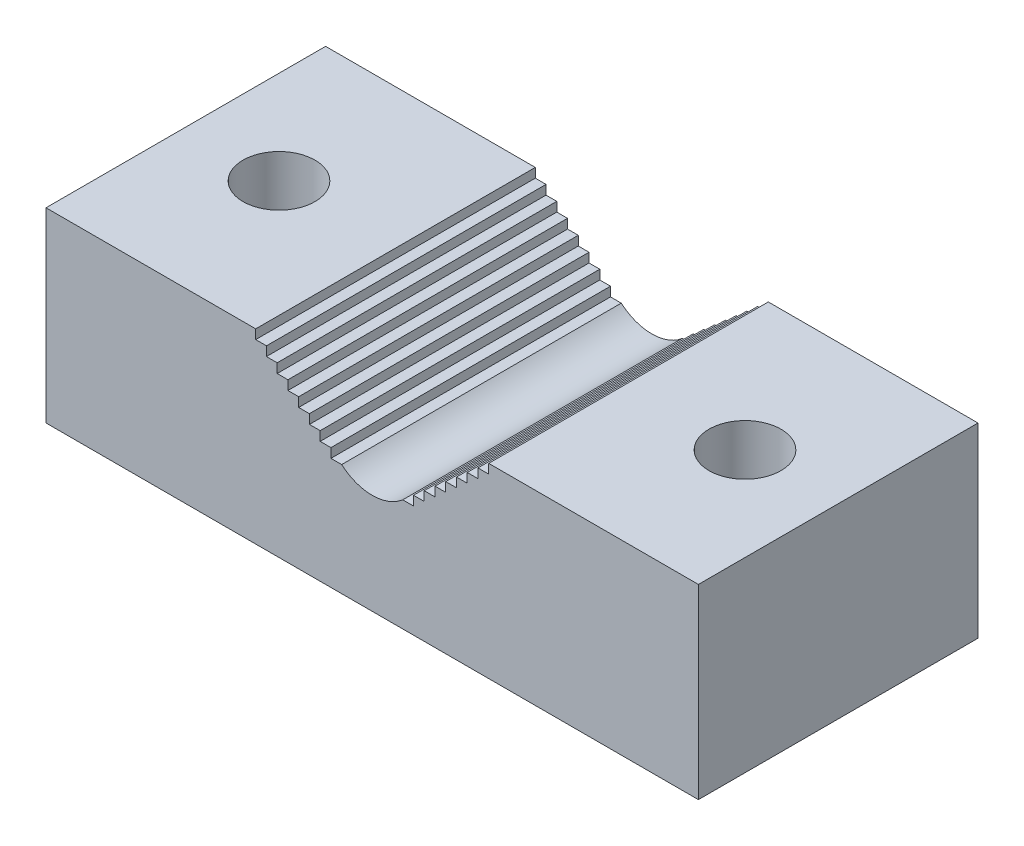
from build123d import *

# Parameters (mm, degrees)
SKETCH1_W               = 88.9
SKETCH1_H               = 25.4
BOSS_EXTRUDE1_DEPTH     = 38.1
CUT_EXTRUDE1_REACH      = 40.1
F_3_8_CLEARANCE_HOLE1_D = 9.8044


with BuildPart() as part:
    # Sketch1 → Boss-Extrude1 (new body)
    with BuildSketch(Plane.XY):
        with Locations((0, 12.7)):
            Rectangle(SKETCH1_W, SKETCH1_H)
    extrude(amount=-BOSS_EXTRUDE1_DEPTH)

    # Sketch2 → Cut-Extrude1 (cut, up to next)
    with BuildSketch(Plane.XY, mode=Mode.PRIVATE) as cut_extrude1_sk1:
        with BuildLine():
            Line((-15.875, 25.4), (0, 25.4))
            Line((0, 25.4), (15.875, 25.4))
            Line((15.875, 25.4), (15.875, 24.13))
            Line((15.875, 24.13), (14.410694861, 24.13))
            Line((14.410694861, 24.13), (14.410694861, 22.86))
            Line((14.410694861, 22.86), (12.946389723, 22.86))
            Line((12.946389723, 22.86), (12.946389723, 21.59))
            Line((12.946389723, 21.59), (11.482084584, 21.59))
            Line((11.482084584, 21.59), (11.482084584, 20.32))
            Line((11.482084584, 20.32), (10.017779445, 20.32))
            Line((10.017779445, 20.32), (10.017779445, 19.05))
            Line((10.017779445, 19.05), (8.553474306, 19.05))
            Line((8.553474306, 19.05), (8.553474306, 17.78))
            Line((8.553474306, 17.78), (7.089169168, 17.78))
            Line((7.089169168, 17.78), (7.089169168, 16.51))
            Line((7.089169168, 16.51), (5.624864029, 16.51))
            Line((5.624864029, 16.51), (5.624864029, 15.24))
            Line((5.624864029, 15.24), (4.16055889, 15.24))
            ThreePointArc((4.16055889, 15.24), (0, 13.687108475), (-4.16055889, 15.24))
            Line((-4.16055889, 15.24), (-5.624864029, 15.24))
            Line((-5.624864029, 15.24), (-5.624864029, 16.51))
            Line((-5.624864029, 16.51), (-7.089169168, 16.51))
            Line((-7.089169168, 16.51), (-7.089169168, 17.78))
            Line((-7.089169168, 17.78), (-8.553474306, 17.78))
            Line((-8.553474306, 17.78), (-8.553474306, 19.05))
            Line((-8.553474306, 19.05), (-10.017779445, 19.05))
            Line((-10.017779445, 19.05), (-10.017779445, 20.32))
            Line((-10.017779445, 20.32), (-11.482084584, 20.32))
            Line((-11.482084584, 20.32), (-11.482084584, 21.59))
            Line((-11.482084584, 21.59), (-12.946389723, 21.59))
            Line((-12.946389723, 21.59), (-12.946389723, 22.86))
            Line((-12.946389723, 22.86), (-14.410694861, 22.86))
            Line((-14.410694861, 22.86), (-14.410694861, 24.13))
            Line((-14.410694861, 24.13), (-15.875, 24.13))
            Line((-15.875, 24.13), (-15.875, 25.4))
        make_face()
    cut_extrude1_tool1 = extrude(cut_extrude1_sk1.sketch, amount=-CUT_EXTRUDE1_REACH, mode=Mode.PRIVATE) & part.part
    add(cut_extrude1_tool1.solids().sort_by_distance((0, 20.970592, 0))[0], mode=Mode.SUBTRACT)

    # 3/8 Clearance Hole1 (through all)
    with Locations(Plane(origin=(0, 25.4, 0), x_dir=(1, 0, 0), z_dir=(0, 1, 0))):
        with Locations((-31.75, 19.05), (31.75, 19.05)):
            Hole(F_3_8_CLEARANCE_HOLE1_D / 2)


solid = part.part
